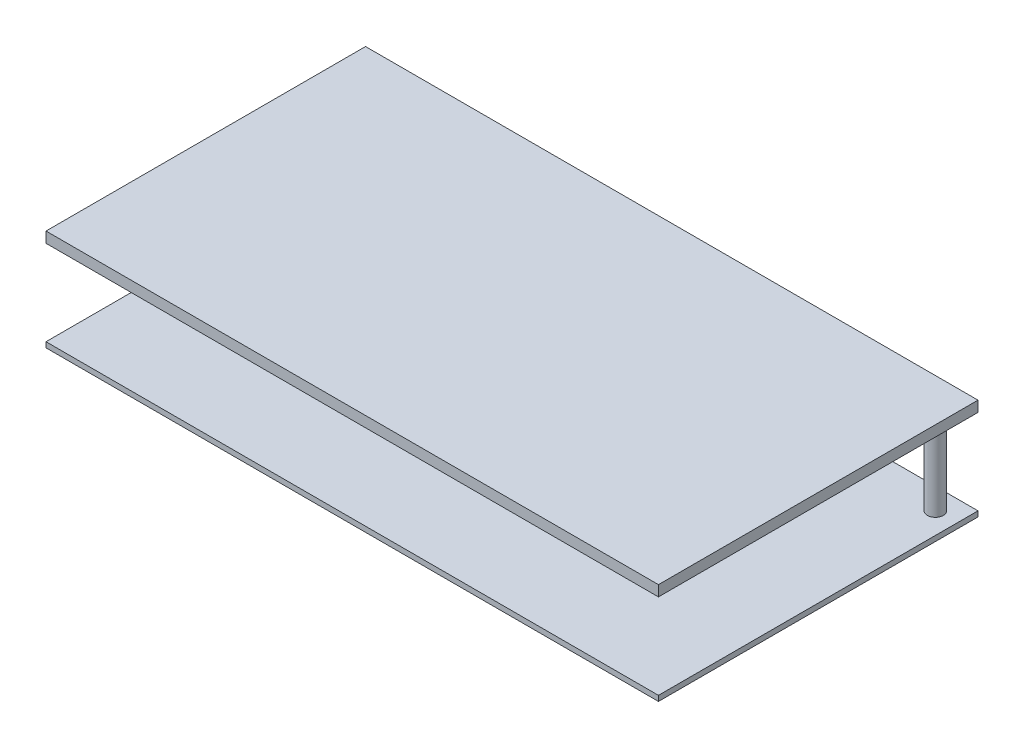
from build123d import *

# Parameters (mm, degrees)
ESTRUSIONE_ESTRUSIONE1_START = 17
SCHIZZO1_W                   = 115
SCHIZZO1_H                   = 60
ESTRUSIONE_ESTRUSIONE1_DEPTH = 2
SCHIZZO5_R                   = 1.5
ESTRUSIONE_ESTRUSIONE2_DEPTH = 19
SCHIZZO6_R                   = 1.5
ESTRUSIONE_ESTRUSIONE3_DEPTH = 19
SCHIZZO1_3_W                 = 115
SCHIZZO1_3_H                 = 60
ESTRUSIONE_ESTRUSIONE4_DEPTH = 1


with BuildPart() as part:
    # Schizzo1 → Estrusione-Estrusione1 (new body)
    with BuildSketch(Plane(origin=(0, 2, 0), x_dir=(1, 0, 0), z_dir=(0, 1, 0)).offset(ESTRUSIONE_ESTRUSIONE1_START)):
        with Locations((-164.562548693, 37.708245302)):
            Rectangle(SCHIZZO1_W, SCHIZZO1_H)
    extrude(amount=ESTRUSIONE_ESTRUSIONE1_DEPTH)

    # Schizzo5 → Estrusione-Estrusione2 (add)
    with BuildSketch(Plane(origin=(0, 21, 0), x_dir=(1, 0, 0), z_dir=(0, 1, 0))):
        with Locations((-111.062548693, 63.708245302)):
            Circle(SCHIZZO5_R)
    extrude(amount=-ESTRUSIONE_ESTRUSIONE2_DEPTH)

    # Schizzo6 → Estrusione-Estrusione3 (add)
    with BuildSketch(Plane(origin=(0, 21, 0), x_dir=(1, 0, 0), z_dir=(0, 1, 0))):
        with Locations((-192.062548693, 63.708245302)):
            Circle(SCHIZZO6_R)
    extrude(amount=-ESTRUSIONE_ESTRUSIONE3_DEPTH)

    # Schizzo1_3 → Estrusione-Estrusione4 (add)
    with BuildSketch(Plane(origin=(0, 2, 0), x_dir=(1, 0, 0), z_dir=(0, 1, 0))):
        with Locations((-164.562548693, 37.708245302)):
            Rectangle(SCHIZZO1_3_W, SCHIZZO1_3_H)
    extrude(amount=ESTRUSIONE_ESTRUSIONE4_DEPTH)


solid = part.part
